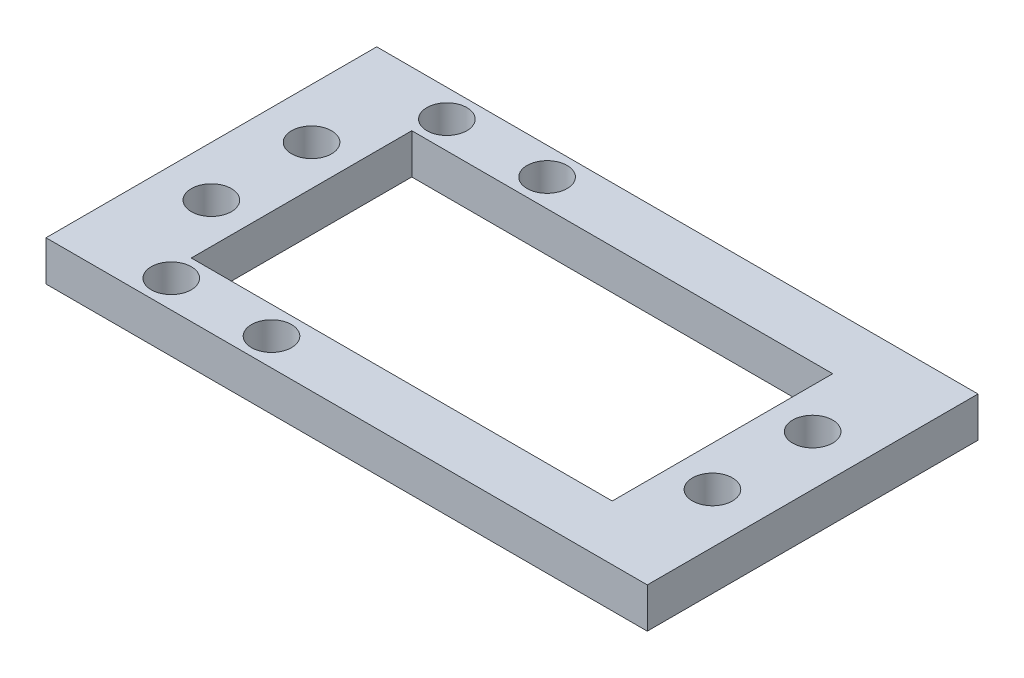
from build123d import *

# Parameters (mm, degrees)
SALIENTE_EXTRUIR1_DEPTH = 40
CROQUIS3_R              = 2.5
CORTAR_EXTRUIR1_DEPTH   = 94
CROQUIS5_W              = 40
CROQUIS5_H              = 10
CORTAR_EXTRUIR2_DEPTH   = 40
CROQUIS6_W              = 42
CROQUIS6_H              = 22
CORTAR_EXTRUIR3_DEPTH   = 10
CROQUIS7_R              = 2
CORTAR_EXTRUIR4_DEPTH   = 10
CROQUIS8_W              = 60
CROQUIS8_H              = 33
CROQUIS8_R              = 2
CROQUIS8_W_2            = 42
CROQUIS8_H_2            = 22
SALIENTE_EXTRUIR2_DEPTH = 4
CROQUIS9_W              = 99.924242424
CROQUIS9_H              = 56.811688312
CORTAR_EXTRUIR9_DEPTH   = 41


with BuildPart() as part:
    # Croquis2 → Saliente-Extruir1 (new body)
    with BuildSketch(Plane.XY):
        Polygon((-31.145916957, -11.001243781), (-31.145916957, 23.998756219), (53.854083043, 23.998756219), (53.854083043, -11.001243781), (57.854083043, -11.001243781), (57.854083043, 27.998756219), (-35.145916957, 27.998756219), (-35.145916957, -11.001243781), align=None)
    extrude(amount=SALIENTE_EXTRUIR1_DEPTH)

    # Croquis3 → Cortar-Extruir1 (cut, through all)
    with BuildSketch(Plane.ZY.offset(35.145916957)):
        with Locations((20, 7.998756219)):
            Circle(CROQUIS3_R)
    extrude(amount=-CORTAR_EXTRUIR1_DEPTH, mode=Mode.SUBTRACT)

    # Croquis5 → Cortar-Extruir2 (cut)
    with BuildSketch(Plane.ZY.offset(35.145916957)):
        with Locations((20, -6.001243781)):
            Rectangle(CROQUIS5_W, CROQUIS5_H)
    extrude(amount=-CORTAR_EXTRUIR2_DEPTH, mode=Mode.SUBTRACT)

    # Croquis6 → Cortar-Extruir3 (cut)
    with BuildSketch(Plane(origin=(0, 27.998756219, 0), x_dir=(1, 0, 0), z_dir=(0, 1, 0))):
        with Locations((11.354083043, -20)):
            Rectangle(CROQUIS6_W, CROQUIS6_H)
    extrude(amount=-CORTAR_EXTRUIR3_DEPTH, mode=Mode.SUBTRACT)

    # Croquis7 → Cortar-Extruir4 (cut)
    with BuildSketch(Plane(origin=(0, 27.998756219, 0), x_dir=(1, 0, 0), z_dir=(0, 1, 0))):
        with Locations((-13.645916957, -15)):
            Circle(CROQUIS7_R)
        with Locations((-13.645916957, -25)):
            Circle(CROQUIS7_R)
        with Locations((36.354083043, -15)):
            Circle(CROQUIS7_R)
        with Locations((36.354083043, -25)):
            Circle(CROQUIS7_R)
    extrude(amount=-CORTAR_EXTRUIR4_DEPTH, mode=Mode.SUBTRACT)

    # Croquis8 → Saliente-Extruir2 (add)
    with BuildSketch(Plane(origin=(0, 27.998756219, 0), x_dir=(1, 0, 0), z_dir=(0, 1, 0))):
        with Locations((11.354083043, -20)):
            Rectangle(CROQUIS8_W, CROQUIS8_H)
        with Locations((-8.895916957, -6.25)):
            Circle(CROQUIS8_R, mode=Mode.SUBTRACT)
        with Locations((1.104083043, -6.25)):
            Circle(CROQUIS8_R, mode=Mode.SUBTRACT)
        with Locations((-8.895916957, -33.75)):
            Circle(CROQUIS8_R, mode=Mode.SUBTRACT)
        with Locations((1.104083043, -33.75)):
            Circle(CROQUIS8_R, mode=Mode.SUBTRACT)
        with Locations((-13.645916957, -15)):
            Circle(CROQUIS8_R, mode=Mode.SUBTRACT)
        with Locations((-13.645916957, -25)):
            Circle(CROQUIS8_R, mode=Mode.SUBTRACT)
        with Locations((36.354083043, -15)):
            Circle(CROQUIS8_R, mode=Mode.SUBTRACT)
        with Locations((36.354083043, -25)):
            Circle(CROQUIS8_R, mode=Mode.SUBTRACT)
        with Locations((11.354083043, -20)):
            Rectangle(CROQUIS8_W_2, CROQUIS8_H_2, mode=Mode.SUBTRACT)
    extrude(amount=SALIENTE_EXTRUIR2_DEPTH)

    # Croquis9 → Cortar-Extruir9 (cut, through all)
    with BuildSketch(Plane.XY.offset(40)):
        with Locations((14.816204255, -0.407087937)):
            Rectangle(CROQUIS9_W, CROQUIS9_H)
    extrude(amount=-CORTAR_EXTRUIR9_DEPTH, mode=Mode.SUBTRACT)


solid = part.part
